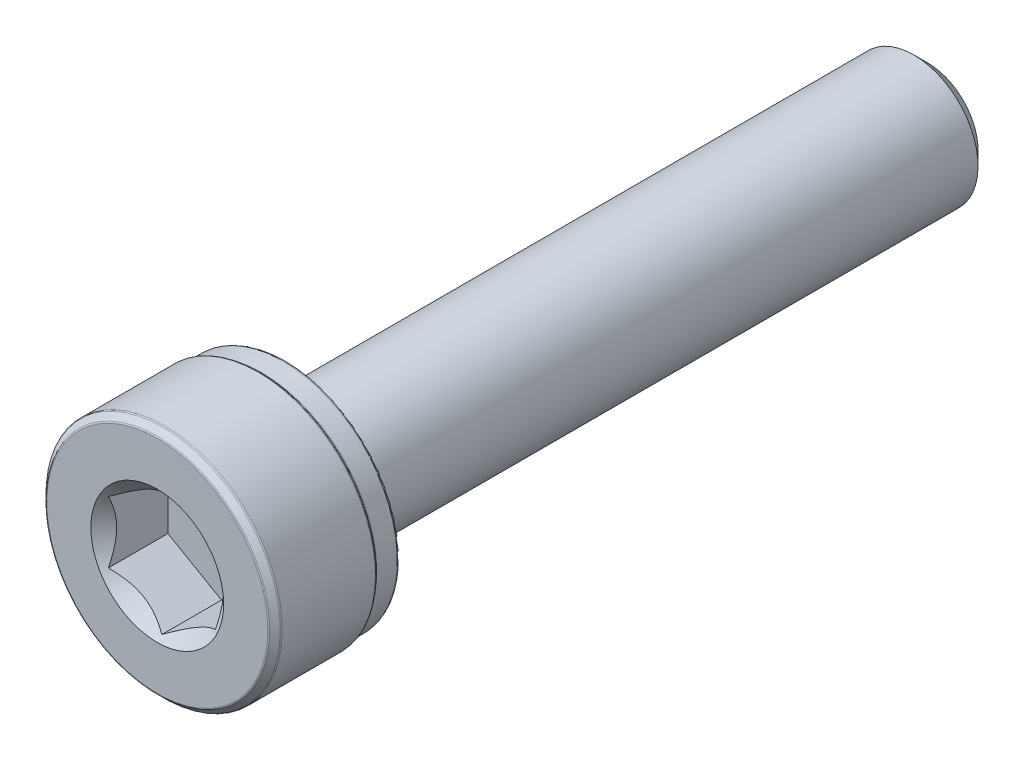
from build123d import *

# Parameters (mm, degrees)
CUT_EXTRUDE1_START = -1.5
CUT_EXTRUDE1_DEPTH = 1.5
SKETCH4_R          = 1.551628848
CUT_EXTRUDE2_DEPTH = 1.5
CUT_EXTRUDE2_TAPER = 45


with BuildPart() as part:
    # Sketch2 → Revolve1 (revolve)
    with BuildSketch(Plane(origin=(0, 0, 0), x_dir=(0, 0, -1), z_dir=(1, 0, 0))):
        with BuildLine():
            Line((-9, 0), (-9, 2.580583739))
            ThreePointArc((-9, 2.580583739), (-8.996431853, 2.598522025), (-8.98627063, 2.61372937))
            Line((-8.98627063, 2.61372937), (-8.86372937, 2.73627063))
            ThreePointArc((-8.86372937, 2.73627063), (-8.848522025, 2.746431853), (-8.830583739, 2.75))
            Line((-8.830583739, 2.75), (-6.656916261, 2.75))
            ThreePointArc((-6.656916261, 2.75), (-6.638977975, 2.746431853), (-6.62377063, 2.73627063))
            Line((-6.62377063, 2.73627063), (-6.57622937, 2.68872937))
            ThreePointArc((-6.57622937, 2.68872937), (-6.561022025, 2.678568147), (-6.543083739, 2.675))
            Line((-6.543083739, 2.675), (-6.06875, 2.675))
            ThreePointArc((-6.06875, 2.675), (-6.020136409, 2.654863591), (-6, 2.60625))
            Line((-6, 2.60625), (-6, 1.65))
            ThreePointArc((-6, 1.65), (-5.956066017, 1.543933983), (-5.85, 1.5))
            Line((-5.85, 1.5), (8.675240474, 1.5))
            Line((8.675240474, 1.5), (9, 1.175240474))
            Line((9, 1.175240474), (9, 0))
            Line((9, 0), (-9, 0))
        make_face()
    revolve(axis=Axis((0, 0, -9), (0, 0, 1)))

    # Sketch3 → Cut-Extrude1 (cut)
    with BuildSketch(Plane.XY.offset(9).offset(CUT_EXTRUDE1_START)):
        Polygon((1.25, -0.721687836), (1.25, 0.721687836), (0, 1.443375673), (-1.25, 0.721687836), (-1.25, -0.721687836), (0, -1.443375673), align=None)
    extrude(amount=CUT_EXTRUDE1_DEPTH, mode=Mode.SUBTRACT)

    # Sketch4 → Cut-Extrude2 (cut)
    with BuildSketch(Plane.XY.offset(9)):
        Circle(SKETCH4_R)
    extrude(amount=-CUT_EXTRUDE2_DEPTH, taper=CUT_EXTRUDE2_TAPER, mode=Mode.SUBTRACT)


solid = part.part
